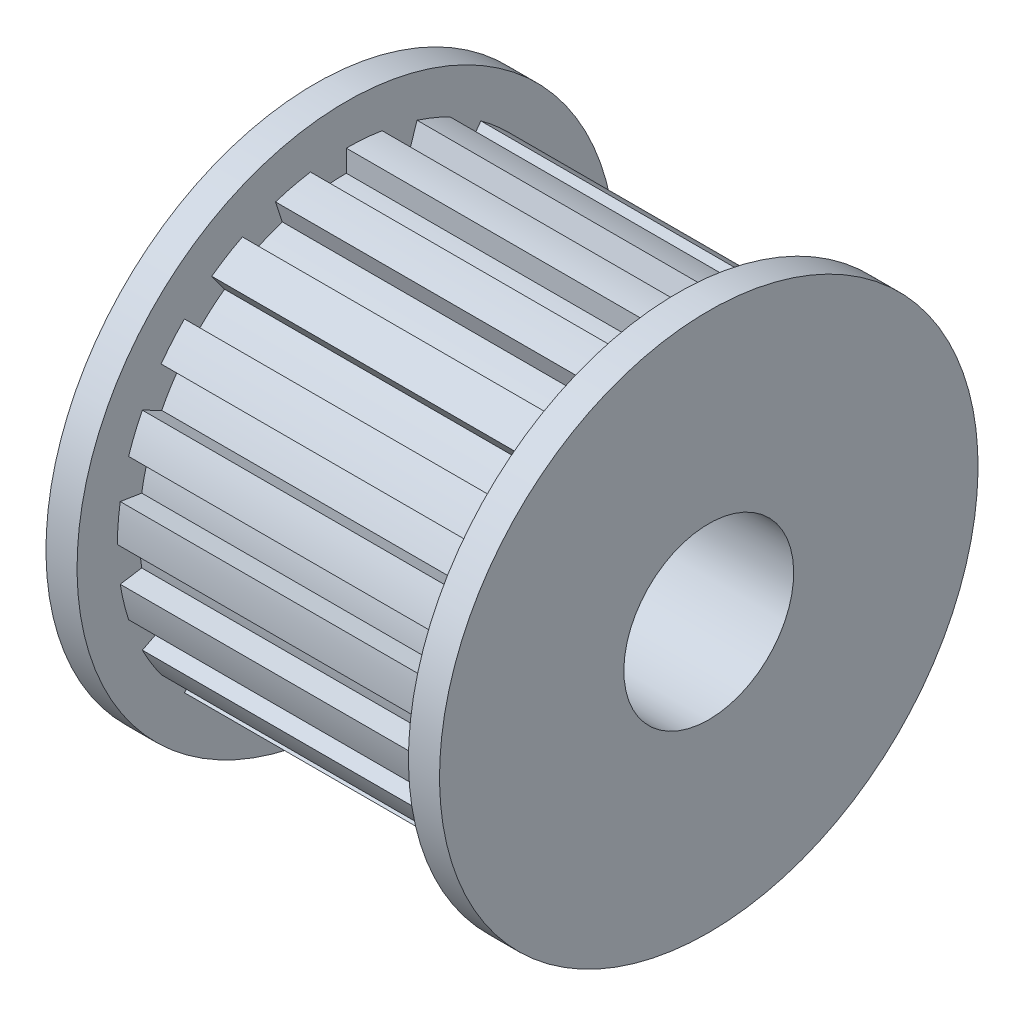
from build123d import *

# Parameters (mm, degrees)
CUT_EXTRUDE_1_DEPTH = 8
SKETCH_7_R          = 4.1
CUT_EXTRUDE_3_DEPTH = 10


with BuildPart() as part:
    # 草图1 → 旋转1 (revolve)
    with BuildSketch(Plane.XY):
        Polygon((-9.5, 0), (9.5, 0), (9.5, 13), (8, 13), (8, 11.05), (-8, 11.05), (-8, 13), (-9.5, 13), align=None)
    revolve(axis=Axis((-9.5, 0, 0), (1, 0, 0)))

    # 草图2 → 切除-拉伸1 (cut, symmetric)
    with BuildSketch(Plane(origin=(0, 0, 0), x_dir=(0, 0, -1), z_dir=(1, 0, 0))):
        with BuildLine():
            Line((11.05, 0), (10, 0))
            ThreePointArc((10, 0), (9.969173337, 0.784590957), (9.876883406, 1.56434465))
            Line((9.876883406, 1.56434465), (10.913956164, 1.728600839))
            ThreePointArc((10.913956164, 1.728600839), (11.015936538, 0.866973008), (11.05, 0))
        make_face()
        with BuildLine():
            Line((10.509174505, -3.414637788), (9.510565163, -3.090169944))
            ThreePointArc((9.510565163, -3.090169944), (9.723699204, -2.334453639), (9.876883406, -1.56434465))
            Line((9.876883406, -1.56434465), (10.913956164, -1.728600839))
            ThreePointArc((10.913956164, -1.728600839), (10.74468762, -2.579571271), (10.509174505, -3.414637788))
        make_face()
        with BuildLine():
            Line((8.939637788, -6.495027038), (8.090169944, -5.877852523))
            ThreePointArc((8.090169944, -5.877852523), (8.526401644, -5.224985647), (8.910065242, -4.539904997))
            Line((8.910065242, -4.539904997), (9.845622092, -5.016595022))
            ThreePointArc((9.845622092, -5.016595022), (9.421673816, -5.77360914), (8.939637788, -6.495027038))
        make_face()
        with BuildLine():
            Line((6.495027038, -8.939637788), (5.877852523, -8.090169944))
            ThreePointArc((5.877852523, -8.090169944), (6.494480483, -7.604059656), (7.071067812, -7.071067812))
            Line((7.071067812, -7.071067812), (7.813529932, -7.813529932))
            ThreePointArc((7.813529932, -7.813529932), (7.176400934, -8.40248592), (6.495027038, -8.939637788))
        make_face()
        with BuildLine():
            Line((3.414637788, -10.509174505), (3.090169944, -9.510565163))
            ThreePointArc((3.090169944, -9.510565163), (3.826834324, -9.238795325), (4.539904997, -8.910065242))
            Line((4.539904997, -8.910065242), (5.016595022, -9.845622092))
            ThreePointArc((5.016595022, -9.845622092), (4.228651928, -10.208868834), (3.414637788, -10.509174505))
        make_face()
        with BuildLine():
            Line((0, -11.05), (0, -10))
            ThreePointArc((0, -10), (0.784590957, -9.969173337), (1.56434465, -9.876883406))
            Line((1.56434465, -9.876883406), (1.728600839, -10.913956164))
            ThreePointArc((1.728600839, -10.913956164), (0.866973008, -11.015936538), (0, -11.05))
        make_face()
        with BuildLine():
            Line((-3.414637788, -10.509174505), (-3.090169944, -9.510565163))
            ThreePointArc((-3.090169944, -9.510565163), (-2.334453639, -9.723699204), (-1.56434465, -9.876883406))
            Line((-1.56434465, -9.876883406), (-1.728600839, -10.913956164))
            ThreePointArc((-1.728600839, -10.913956164), (-2.579571271, -10.74468762), (-3.414637788, -10.509174505))
        make_face()
        with BuildLine():
            Line((-6.495027038, -8.939637788), (-5.877852523, -8.090169944))
            ThreePointArc((-5.877852523, -8.090169944), (-5.224985647, -8.526401644), (-4.539904997, -8.910065242))
            Line((-4.539904997, -8.910065242), (-5.016595022, -9.845622092))
            ThreePointArc((-5.016595022, -9.845622092), (-5.77360914, -9.421673816), (-6.495027038, -8.939637788))
        make_face()
        with BuildLine():
            Line((-8.939637788, -6.495027038), (-8.090169944, -5.877852523))
            ThreePointArc((-8.090169944, -5.877852523), (-7.604059656, -6.494480483), (-7.071067812, -7.071067812))
            Line((-7.071067812, -7.071067812), (-7.813529932, -7.813529932))
            ThreePointArc((-7.813529932, -7.813529932), (-8.40248592, -7.176400934), (-8.939637788, -6.495027038))
        make_face()
        with BuildLine():
            Line((-10.509174505, -3.414637788), (-9.510565163, -3.090169944))
            ThreePointArc((-9.510565163, -3.090169944), (-9.238795325, -3.826834324), (-8.910065242, -4.539904997))
            Line((-8.910065242, -4.539904997), (-9.845622092, -5.016595022))
            ThreePointArc((-9.845622092, -5.016595022), (-10.208868834, -4.228651928), (-10.509174505, -3.414637788))
        make_face()
        with BuildLine():
            Line((-11.05, 0), (-10, 0))
            ThreePointArc((-10, 0), (-9.969173337, -0.784590957), (-9.876883406, -1.56434465))
            Line((-9.876883406, -1.56434465), (-10.913956164, -1.728600839))
            ThreePointArc((-10.913956164, -1.728600839), (-11.015936538, -0.866973008), (-11.05, 0))
        make_face()
        with BuildLine():
            Line((-10.509174505, 3.414637788), (-9.510565163, 3.090169944))
            ThreePointArc((-9.510565163, 3.090169944), (-9.723699204, 2.334453639), (-9.876883406, 1.56434465))
            Line((-9.876883406, 1.56434465), (-10.913956164, 1.728600839))
            ThreePointArc((-10.913956164, 1.728600839), (-10.74468762, 2.579571271), (-10.509174505, 3.414637788))
        make_face()
        with BuildLine():
            Line((-8.939637788, 6.495027038), (-8.090169944, 5.877852523))
            ThreePointArc((-8.090169944, 5.877852523), (-8.526401644, 5.224985647), (-8.910065242, 4.539904997))
            Line((-8.910065242, 4.539904997), (-9.845622092, 5.016595022))
            ThreePointArc((-9.845622092, 5.016595022), (-9.421673816, 5.77360914), (-8.939637788, 6.495027038))
        make_face()
        with BuildLine():
            Line((-6.495027038, 8.939637788), (-5.877852523, 8.090169944))
            ThreePointArc((-5.877852523, 8.090169944), (-6.494480483, 7.604059656), (-7.071067812, 7.071067812))
            Line((-7.071067812, 7.071067812), (-7.813529932, 7.813529932))
            ThreePointArc((-7.813529932, 7.813529932), (-7.176400934, 8.40248592), (-6.495027038, 8.939637788))
        make_face()
        with BuildLine():
            Line((-3.414637788, 10.509174505), (-3.090169944, 9.510565163))
            ThreePointArc((-3.090169944, 9.510565163), (-3.826834324, 9.238795325), (-4.539904997, 8.910065242))
            Line((-4.539904997, 8.910065242), (-5.016595022, 9.845622092))
            ThreePointArc((-5.016595022, 9.845622092), (-4.228651928, 10.208868834), (-3.414637788, 10.509174505))
        make_face()
        with BuildLine():
            Line((0, 11.05), (0, 10))
            ThreePointArc((0, 10), (-0.784590957, 9.969173337), (-1.56434465, 9.876883406))
            Line((-1.56434465, 9.876883406), (-1.728600839, 10.913956164))
            ThreePointArc((-1.728600839, 10.913956164), (-0.866973008, 11.015936538), (0, 11.05))
        make_face()
        with BuildLine():
            Line((3.414637788, 10.509174505), (3.090169944, 9.510565163))
            ThreePointArc((3.090169944, 9.510565163), (2.334453639, 9.723699204), (1.56434465, 9.876883406))
            Line((1.56434465, 9.876883406), (1.728600839, 10.913956164))
            ThreePointArc((1.728600839, 10.913956164), (2.579571271, 10.74468762), (3.414637788, 10.509174505))
        make_face()
        with BuildLine():
            Line((6.495027038, 8.939637788), (5.877852523, 8.090169944))
            ThreePointArc((5.877852523, 8.090169944), (5.224985647, 8.526401644), (4.539904997, 8.910065242))
            Line((4.539904997, 8.910065242), (5.016595022, 9.845622092))
            ThreePointArc((5.016595022, 9.845622092), (5.77360914, 9.421673816), (6.495027038, 8.939637788))
        make_face()
        with BuildLine():
            Line((8.939637788, 6.495027038), (8.090169944, 5.877852523))
            ThreePointArc((8.090169944, 5.877852523), (7.604059656, 6.494480483), (7.071067812, 7.071067812))
            Line((7.071067812, 7.071067812), (7.813529932, 7.813529932))
            ThreePointArc((7.813529932, 7.813529932), (8.40248592, 7.176400934), (8.939637788, 6.495027038))
        make_face()
        with BuildLine():
            Line((10.509174505, 3.414637788), (9.510565163, 3.090169944))
            ThreePointArc((9.510565163, 3.090169944), (9.238795325, 3.826834324), (8.910065242, 4.539904997))
            Line((8.910065242, 4.539904997), (9.845622092, 5.016595022))
            ThreePointArc((9.845622092, 5.016595022), (10.208868834, 4.228651928), (10.509174505, 3.414637788))
        make_face()
    extrude(amount=CUT_EXTRUDE_1_DEPTH, both=True, mode=Mode.SUBTRACT)

    # 草图7 → 切除-拉伸3 (cut, symmetric)
    with BuildSketch(Plane(origin=(0, 0, 0), x_dir=(0, 0, -1), z_dir=(1, 0, 0))):
        Circle(SKETCH_7_R)
    extrude(amount=CUT_EXTRUDE_3_DEPTH, both=True, mode=Mode.SUBTRACT)


solid = part.part
